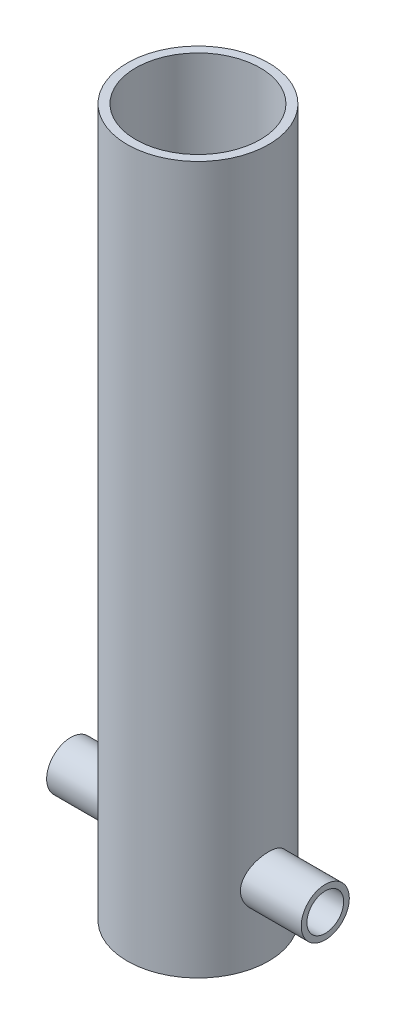
from build123d import *

# Parameters (mm, degrees)
SKETCH2_R                = 25
SKETCH2_R_2              = 22
BOSS_EXTRUDE1_DEPTH      = 250
SKETCH3_R                = 8.5
SKETCH3_R_2              = 6.5
BOSS_EXTRUDE2_DEPTH      = 45
BOSS_EXTRUDE2_DEPTH_BACK = 45


with BuildPart() as part:
    # Sketch2 → Boss-Extrude1 (new body)
    with BuildSketch(Plane(origin=(0, 0, 0), x_dir=(1, 0, 0), z_dir=(0, 1, 0))):
        Circle(SKETCH2_R)
        Circle(SKETCH2_R_2, mode=Mode.SUBTRACT)
    extrude(amount=BOSS_EXTRUDE1_DEPTH)

    # Sketch3 → Boss-Extrude2 (add, two sides)
    with BuildSketch(Plane(origin=(0, 0, 0), x_dir=(0, 0, -1), z_dir=(1, 0, 0))) as boss_extrude2_sk:
        with Locations((0, 25)):
            Circle(SKETCH3_R)
        with Locations((0, 25)):
            Circle(SKETCH3_R_2, mode=Mode.SUBTRACT)
    extrude(amount=BOSS_EXTRUDE2_DEPTH)
    extrude(boss_extrude2_sk.sketch, amount=-BOSS_EXTRUDE2_DEPTH_BACK)


solid = part.part
